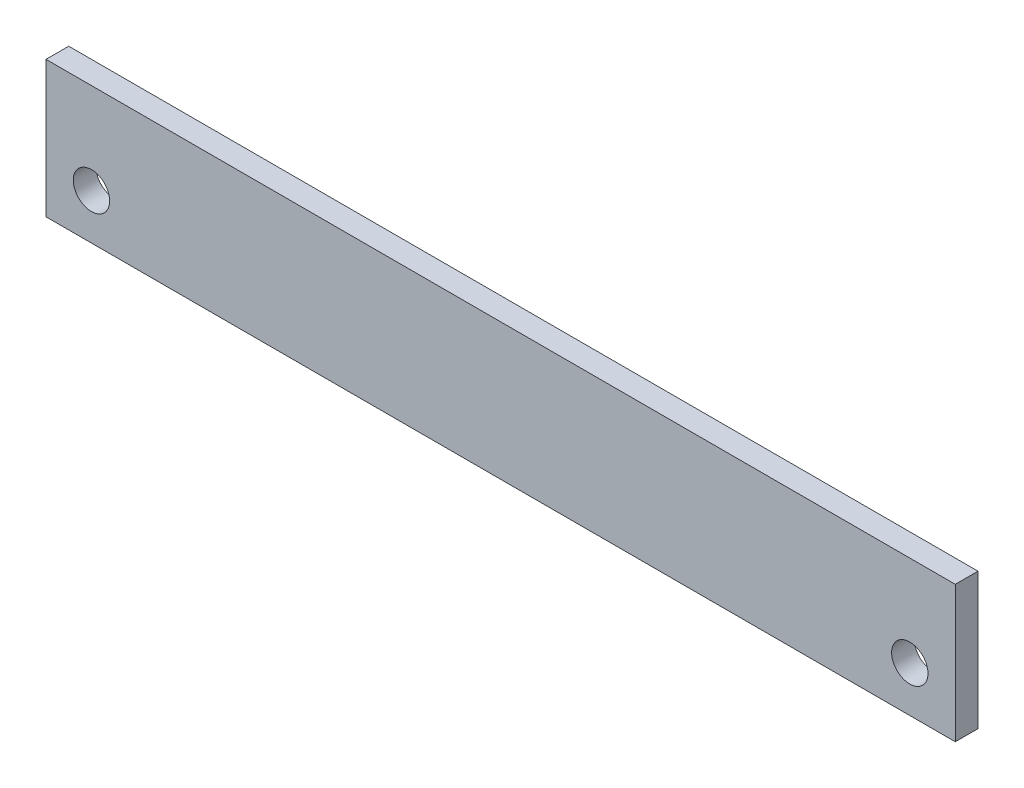
from build123d import *

# Parameters (mm, degrees)
SKETCH1_W           = 200
SKETCH1_H           = 30
BOSS_EXTRUDE1_DEPTH = 5
SKETCH2_R           = 4
CUT_EXTRUDE1_DEPTH  = 5


with BuildPart() as part:
    # Sketch1 → Boss-Extrude1 (new body)
    with BuildSketch(Plane.XY):
        Rectangle(SKETCH1_W, SKETCH1_H)
    extrude(amount=BOSS_EXTRUDE1_DEPTH)

    # Sketch2 → Cut-Extrude1 (cut)
    with BuildSketch(Plane.XY.offset(5)):
        with Locations((-90, -5)):
            Circle(SKETCH2_R)
        with Locations((90, -5)):
            Circle(SKETCH2_R)
    extrude(amount=-CUT_EXTRUDE1_DEPTH, mode=Mode.SUBTRACT)


solid = part.part
